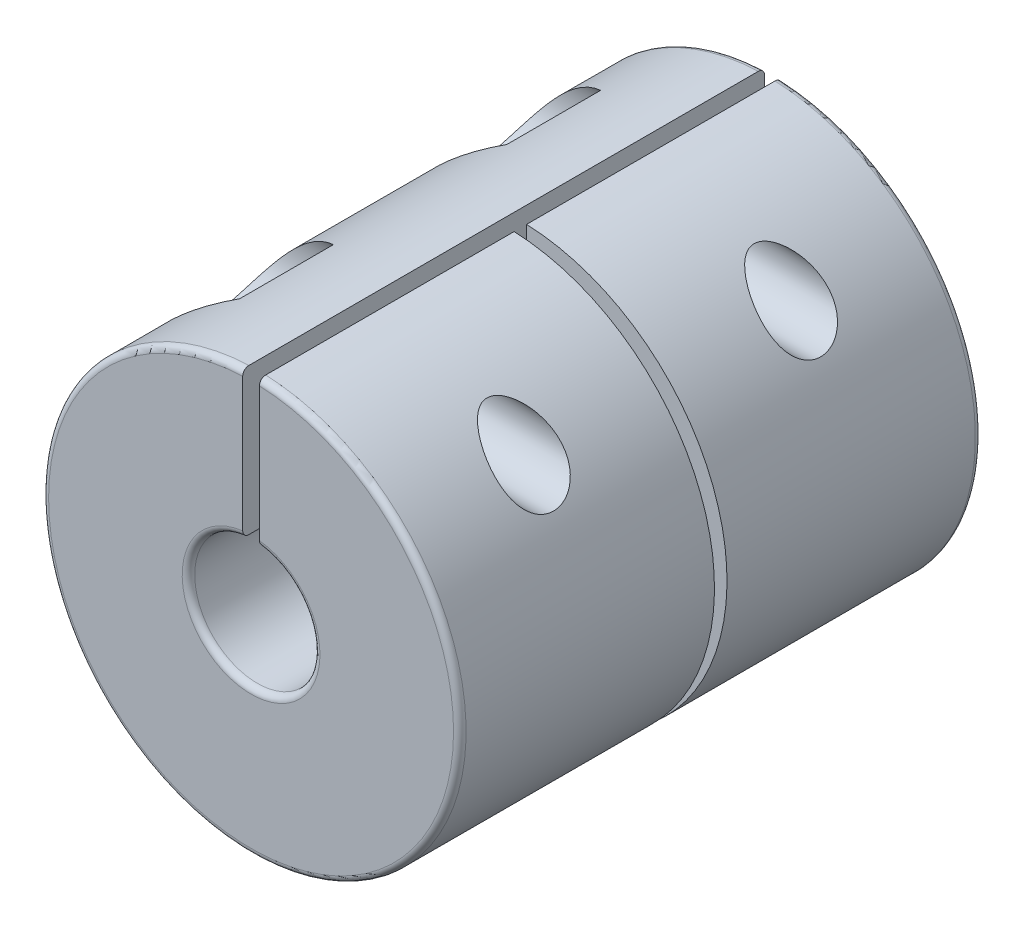
from build123d import *

# Parameters (mm, degrees)
SKETCH_1_R               = 10
EXTRUDE_1_DEPTH          = 12.5
SKETCH_2_R               = 3
CUT_EXTRUDE_1_DEPTH      = 26
SKETCH_3_R               = 4
CUT_EXTRUDE_2_DEPTH      = 12.2
SKETCH_4_R               = 4.5
CUT_EXTRUDE_3_DEPTH      = 0.6
SKETCH_5_W               = 0.8
SKETCH_5_H               = 12
CUT_EXTRUDE_4_DEPTH      = 13.5
CUT_EXTRUDE_4_DEPTH_BACK = 13.5
SKETCH_7_W               = 10
SKETCH_7_H               = 0.6
CUT_EXTRUDE_5_DEPTH      = 10.991996797
CUT_EXTRUDE_5_DEPTH_BACK = 11
SKETCH_8_R               = 1.55
CUT_EXTRUDE_6_DEPTH      = 11.4
CUT_EXTRUDE_6_DEPTH_BACK = 10.6
FILLET_1_R               = 0.3
CUT_EXTRUDE_START        = -4
SKETCH_9_R               = 3
CUT_EXTRUDE_7_DEPTH      = 6.6000001


with BuildPart() as part:
    # 草图1 → 凸台-拉伸1 (new body, symmetric)
    with BuildSketch(Plane.XY):
        Circle(SKETCH_1_R)
    extrude(amount=EXTRUDE_1_DEPTH, both=True)

    # 草图2 → 切除-拉伸1 (cut, through all)
    with BuildSketch(Plane.XY.offset(12.5)):
        Circle(SKETCH_2_R)
    extrude(amount=-CUT_EXTRUDE_1_DEPTH, mode=Mode.SUBTRACT)

    # 草图3 → 切除-拉伸2 (cut)
    with BuildSketch(Plane(origin=(0, 0, -12.5), x_dir=(-1, 0, 0), z_dir=(0, 0, -1))):
        Circle(SKETCH_3_R)
    extrude(amount=-CUT_EXTRUDE_2_DEPTH, mode=Mode.SUBTRACT)

    # 草图4 → 切除-拉伸3 (cut)
    with BuildSketch(Plane(origin=(0, 0, -0.3), x_dir=(-1, 0, 0), z_dir=(0, 0, -1))):
        Circle(SKETCH_4_R)
    extrude(amount=-CUT_EXTRUDE_3_DEPTH, mode=Mode.SUBTRACT)

    # 草图5 → 切除-拉伸4 (cut, two sides)
    with BuildSketch(Plane.XY) as cut_extrude_4_sk:
        with Locations((0, 6)):
            Rectangle(SKETCH_5_W, SKETCH_5_H)
    extrude(amount=CUT_EXTRUDE_4_DEPTH, mode=Mode.SUBTRACT)
    extrude(cut_extrude_4_sk.sketch, amount=-CUT_EXTRUDE_4_DEPTH_BACK, mode=Mode.SUBTRACT)

    # 草图7 → 切除-拉伸5 (cut, two sides)
    with BuildSketch(Plane(origin=(0, 0, 0), x_dir=(1, 0, 0), z_dir=(0, 1, 0))) as cut_extrude_5_sk:
        with Locations((5, 0)):
            Rectangle(SKETCH_7_W, SKETCH_7_H)
    extrude(amount=CUT_EXTRUDE_5_DEPTH, mode=Mode.SUBTRACT)
    extrude(cut_extrude_5_sk.sketch, amount=-CUT_EXTRUDE_5_DEPTH_BACK, mode=Mode.SUBTRACT)

    # 草图8 → 切除-拉伸6 (cut, two sides)
    with BuildSketch(Plane(origin=(-0.4, 0, 0), x_dir=(0, 0, -1), z_dir=(1, 0, 0))) as cut_extrude_6_sk:
        with Locations((6.4, 6.991996797)):
            Circle(SKETCH_8_R)
        with Locations((-6.4, 6.991996797)):
            Circle(SKETCH_8_R)
    extrude(amount=CUT_EXTRUDE_6_DEPTH, mode=Mode.SUBTRACT)
    extrude(cut_extrude_6_sk.sketch, amount=-CUT_EXTRUDE_6_DEPTH_BACK, mode=Mode.SUBTRACT)

    # 圆角1
    fillet_1_edges = [part.edges().sort_by_distance(p)[0] for p in [
        (0, -4, -12.5),
        (0, -10, -12.5),
        (0, -3, 12.5),
        (0, -10, 12.5),
    ]]
    fillet(fillet_1_edges, radius=FILLET_1_R)

    # 草图9 → 切除-拉伸7 (cut, through all)
    with BuildSketch(Plane(origin=(-0.4, 0, 0), x_dir=(0, 0, -1), z_dir=(1, 0, 0)).offset(CUT_EXTRUDE_START)):
        with Locations((-6.4, 6.991996797)):
            Circle(SKETCH_9_R)
        with Locations((6.4, 6.991996797)):
            Circle(SKETCH_9_R)
    extrude(amount=-CUT_EXTRUDE_7_DEPTH, mode=Mode.SUBTRACT)


solid = part.part
